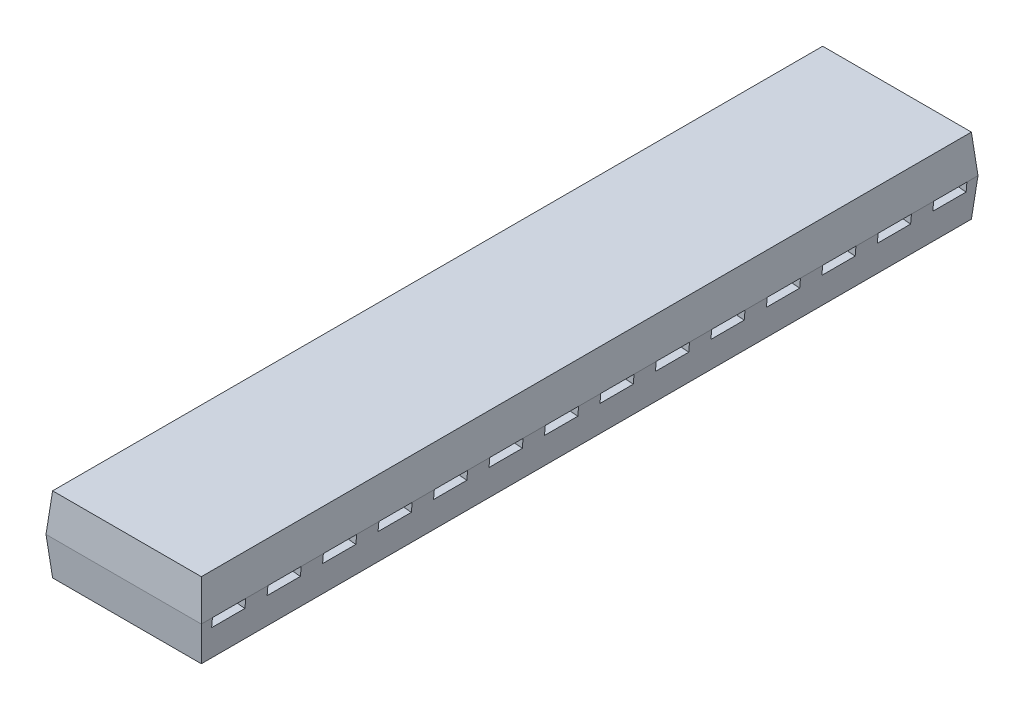
from build123d import *

# Parameters (mm, degrees)
SKETCH1_W                     = 7
SKETCH1_H                     = 35
BOSS_EXTRUDE1_DEPTH           = 1.7
BOSS_EXTRUDE1_TAPER           = 5
BOSS_EXTRUDE1_OTHER_WAY_DEPTH = 1.7
BOSS_EXTRUDE1_OTHER_WAY_TAPER = 5
SKETCH2_W                     = 1.5
SKETCH2_H                     = 0.41
CUT_EXTRUDE1_DEPTH            = 1.7


with BuildPart() as part:
    # Sketch1 → Boss-Extrude1 (new body)
    with BuildSketch(Plane(origin=(0, 0, 0), x_dir=(1, 0, 0), z_dir=(0, 1, 0))):
        with Locations((3.5, 17.5)):
            Rectangle(SKETCH1_W, SKETCH1_H)
    extrude(amount=BOSS_EXTRUDE1_DEPTH, taper=BOSS_EXTRUDE1_TAPER)

    # Sketch1 → Boss-Extrude1 other way (add)
    with BuildSketch(Plane(origin=(0, 0, 0), x_dir=(1, 0, 0), z_dir=(0, 1, 0))):
        with Locations((3.5, 17.5)):
            Rectangle(SKETCH1_W, SKETCH1_H)
    extrude(amount=-BOSS_EXTRUDE1_OTHER_WAY_DEPTH, taper=BOSS_EXTRUDE1_OTHER_WAY_TAPER)

    # Sketch2 → Cut-Extrude1 (cut)
    with BuildSketch(Plane(origin=(6.946827136, -0.607768622, 0), x_dir=(0, 0, -1), z_dir=(0.996194698, -0.087155743, 0))):
        with Locations((1.25, 0.405090199)):
            Rectangle(SKETCH2_W, SKETCH2_H)
        with Locations((3.75, 0.405090199)):
            Rectangle(SKETCH2_W, SKETCH2_H)
        with Locations((6.25, 0.405090199)):
            Rectangle(SKETCH2_W, SKETCH2_H)
        with Locations((8.75, 0.405090199)):
            Rectangle(SKETCH2_W, SKETCH2_H)
        with Locations((11.25, 0.405090199)):
            Rectangle(SKETCH2_W, SKETCH2_H)
        with Locations((13.75, 0.405090199)):
            Rectangle(SKETCH2_W, SKETCH2_H)
        with Locations((16.25, 0.405090199)):
            Rectangle(SKETCH2_W, SKETCH2_H)
        with Locations((18.75, 0.405090199)):
            Rectangle(SKETCH2_W, SKETCH2_H)
        with Locations((21.25, 0.405090199)):
            Rectangle(SKETCH2_W, SKETCH2_H)
        with Locations((23.75, 0.405090199)):
            Rectangle(SKETCH2_W, SKETCH2_H)
        with Locations((26.25, 0.405090199)):
            Rectangle(SKETCH2_W, SKETCH2_H)
        with Locations((28.75, 0.405090199)):
            Rectangle(SKETCH2_W, SKETCH2_H)
        with Locations((31.25, 0.405090199)):
            Rectangle(SKETCH2_W, SKETCH2_H)
        with Locations((33.75, 0.405090199)):
            Rectangle(SKETCH2_W, SKETCH2_H)
    cut_extrude1 = extrude(amount=-CUT_EXTRUDE1_DEPTH, mode=Mode.SUBTRACT)

    # Mirror1: Cut-Extrude1 across plane
    add(cut_extrude1.mirror(Plane(origin=(3.5, 0, 0), x_dir=(0, 0, 1), z_dir=(1, 0, 0))), mode=Mode.SUBTRACT)


solid = part.part
